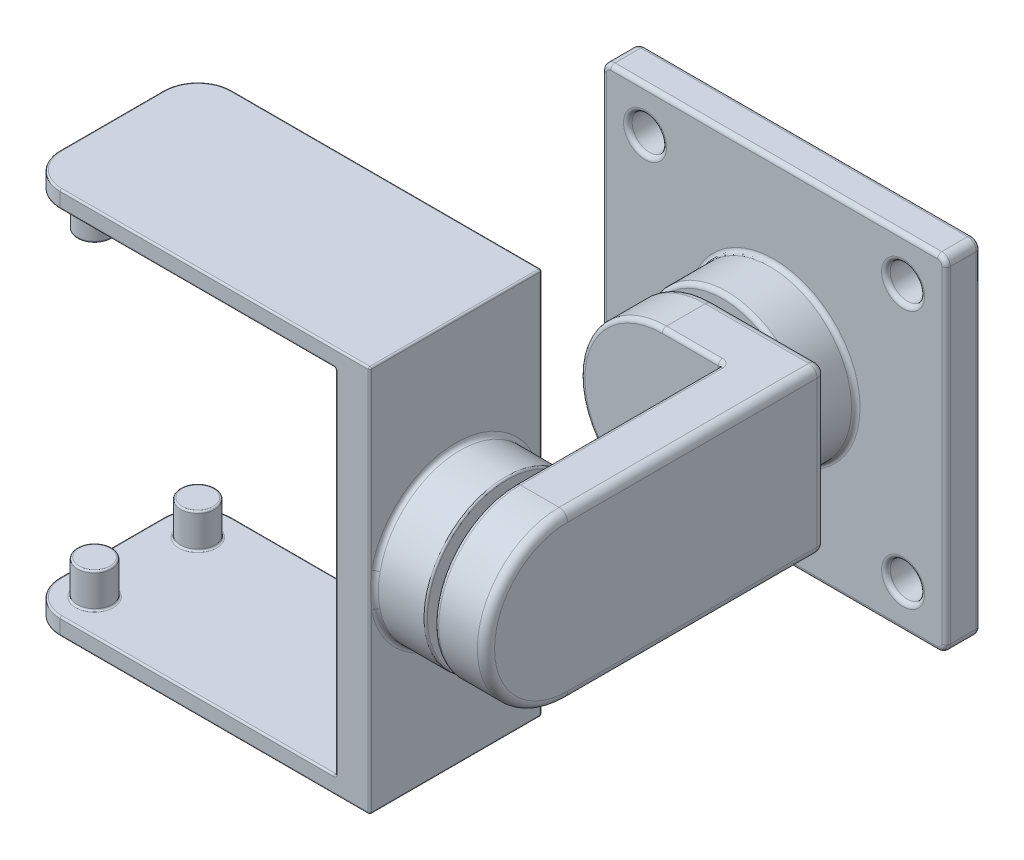
from build123d import *

# Parameters (mm, degrees)
BOSS_EXTRUDE1_DEPTH  = 10
BOSS_EXTRUDE2_START  = -10.25
SKETCH2_R            = 1
BOSS_EXTRUDE2_DEPTH  = 2
BOSS_EXTRUDE3_START  = 10.25
SKETCH2_2_R          = 1
BOSS_EXTRUDE3_DEPTH  = 2
FILLET1_R            = 2
FILLET2_R            = 0.1
SKETCH4_R            = 4.75
BOSS_EXTRUDE4_DEPTH  = 3
FILLET3_R            = 0.1
SKETCH5_R            = 3
BOSS_EXTRUDE5_DEPTH  = 0.5
SKETCH6_R            = 4.75
BOSS_EXTRUDE6_DEPTH  = 3
SKETCH7_W            = 15
SKETCH7_H            = 9.5
BOSS_EXTRUDE7_DEPTH  = 3
BOSS_EXTRUDE8_DEPTH  = 3
SKETCH10_R           = 3
BOSS_EXTRUDE9_DEPTH  = 0.5
SKETCH11_R           = 4.75
BOSS_EXTRUDE10_DEPTH = 3
SKETCH12_W           = 20
SKETCH12_H           = 20
BOSS_EXTRUDE11_DEPTH = 2
FILLET4_R            = 0.5
CUT_EXTRUDE1_REACH   = 27.5
SKETCH13_R           = 1
FILLET5_R            = 0.5
FILLET6_R            = 0.25


with BuildPart() as part:
    # Sketch1 → Boss-Extrude1 (new body)
    with BuildSketch(Plane.XY):
        Polygon((0, -10.25), (0, 10.25), (-18, 10.25), (-18, 11.25), (2, 11.25), (2, -11.25), (-18, -11.25), (-18, -10.25), align=None)
    extrude(amount=BOSS_EXTRUDE1_DEPTH)

    # Sketch2 → Boss-Extrude2 (add)
    with BuildSketch(Plane(origin=(0, 0, 0), x_dir=(1, 0, 0), z_dir=(0, 1, 0)).offset(BOSS_EXTRUDE2_START)):
        with Locations((-16, -2)):
            Circle(SKETCH2_R)
        with Locations((-16, -8)):
            Circle(SKETCH2_R)
    extrude(amount=BOSS_EXTRUDE2_DEPTH)

    # Sketch2_2 → Boss-Extrude3 (add)
    with BuildSketch(Plane(origin=(0, 0, 0), x_dir=(1, 0, 0), z_dir=(0, 1, 0)).offset(BOSS_EXTRUDE3_START)):
        with Locations((-16, -2)):
            Circle(SKETCH2_2_R)
        with Locations((-16, -8)):
            Circle(SKETCH2_2_R)
    extrude(amount=-BOSS_EXTRUDE3_DEPTH)

    # Fillet1
    fillet1_edges = [part.edges().sort_by_distance(p)[0] for p in [
        (-18, 10.75, 0),
        (-18, -10.75, 10),
        (-18, 10.75, 10),
        (-18, -10.75, 0),
    ]]
    fillet(fillet1_edges, radius=FILLET1_R)

    # Fillet2
    fillet2_edges = [part.edges().sort_by_distance(p)[0] for p in [
        (0, 0, 10),
        (-8, -10.25, 10),
        (2, 11.25, 5),
        (2, -11.25, 5),
        (0, -10.25, 5),
        (0, 10.25, 5),
        (2, 0, 10),
        (-17, -8.25, 2),
        (-17, -10.25, 2),
        (-7, 11.25, 10),
        (-17, -8.25, 8),
        (-17, -10.25, 8),
        (-17, 8.25, 2),
        (-17, 10.25, 2),
        (-17, 8.25, 8),
        (-17, 10.25, 8),
        (-8, 10.25, 10),
        (-7, -11.25, 10),
        (-7, -11.25, 0),
        (-18, -11.25, 5),
        (-17.414213562, -11.25, 0.585786438),
        (-17.414213562, -11.25, 9.414213562),
        (-18, -10.25, 5),
        (-17.414213562, -10.25, 0.585786438),
        (-17.414213562, -10.25, 9.414213562),
        (-8, 10.25, 0),
        (-18, 10.25, 5),
        (-17.414213562, 10.25, 0.585786438),
        (-17.414213562, 10.25, 9.414213562),
        (-18, 11.25, 5),
        (-17.414213562, 11.25, 0.585786438),
        (-17.414213562, 11.25, 9.414213562),
        (-7, 11.25, 0),
        (2, 0, 0),
        (-8, -10.25, 0),
        (0, 0, 0),
    ]]
    fillet(fillet2_edges, radius=FILLET2_R)

    # Sketch4 → Boss-Extrude4 (add)
    with BuildSketch(Plane(origin=(2, 0, 0), x_dir=(0, 0, -1), z_dir=(1, 0, 0))):
        with Locations((-5, 0)):
            Circle(SKETCH4_R)
    extrude(amount=BOSS_EXTRUDE4_DEPTH)

    # Fillet3
    fillet3_edges = [part.edges().sort_by_distance(p)[0] for p in [
        (5, 0, 9.75),
    ]]
    fillet(fillet3_edges, radius=FILLET3_R)

    # Sketch5 → Boss-Extrude5 (add)
    with BuildSketch(Plane(origin=(5, 0, 0), x_dir=(0, 0, -1), z_dir=(1, 0, 0))):
        with Locations((-5, 0)):
            Circle(SKETCH5_R)
    extrude(amount=BOSS_EXTRUDE5_DEPTH)

    # Sketch6 → Boss-Extrude6 (add)
    with BuildSketch(Plane(origin=(5.5, 0, 0), x_dir=(0, 0, -1), z_dir=(1, 0, 0))):
        with Locations((-5, 0)):
            Circle(SKETCH6_R)
    extrude(amount=BOSS_EXTRUDE6_DEPTH)

    # Sketch7 → Boss-Extrude7 (add)
    with BuildSketch(Plane(origin=(8.5, 0, 0), x_dir=(0, 0, -1), z_dir=(1, 0, 0))):
        with Locations((2.5, 0)):
            Rectangle(SKETCH7_W, SKETCH7_H)
    extrude(amount=-BOSS_EXTRUDE7_DEPTH)

    # Sketch9 → Boss-Extrude8 (add)
    with BuildSketch(Plane(origin=(0, 0, -10), x_dir=(-1, 0, 0), z_dir=(0, 0, -1))):
        with BuildLine():
            Line((-8.5, 4.75), (-2, 4.75))
            ThreePointArc((-2, 4.75), (2.75, 0), (-2, -4.75))
            Line((-2, -4.75), (-8.5, -4.75))
            Line((-8.5, -4.75), (-8.5, 4.75))
        make_face()
    extrude(amount=-BOSS_EXTRUDE8_DEPTH)

    # Sketch10 → Boss-Extrude9 (add)
    with BuildSketch(Plane(origin=(0, 0, -10), x_dir=(-1, 0, 0), z_dir=(0, 0, -1))):
        with Locations((-2, 0)):
            Circle(SKETCH10_R)
    extrude(amount=BOSS_EXTRUDE9_DEPTH)

    # Sketch11 → Boss-Extrude10 (add)
    with BuildSketch(Plane(origin=(0, 0, -10.5), x_dir=(-1, 0, 0), z_dir=(0, 0, -1))):
        with Locations((-2, 0)):
            Circle(SKETCH11_R)
    extrude(amount=BOSS_EXTRUDE10_DEPTH)

    # Sketch12 → Boss-Extrude11 (add)
    with BuildSketch(Plane(origin=(0, 0, -13.5), x_dir=(-1, 0, 0), z_dir=(0, 0, -1))):
        with Locations((-2, 0)):
            Rectangle(SKETCH12_W, SKETCH12_H)
    extrude(amount=BOSS_EXTRUDE11_DEPTH)

    # Fillet4
    fillet4_edges = [part.edges().sort_by_distance(p)[0] for p in [
        (-8, -10, -14.5),
        (-8, 10, -14.5),
        (12, 10, -14.5),
        (12, -10, -14.5),
    ]]
    fillet(fillet4_edges, radius=FILLET4_R)

    # Sketch13 → Cut-Extrude1 (cut, up to next)
    with BuildSketch(Plane(origin=(0, 0, -15.5), x_dir=(-1, 0, 0), z_dir=(0, 0, -1)), mode=Mode.PRIVATE) as cut_extrude1_sk1:
        with Locations((5.5, 7.5)):
            Circle(SKETCH13_R)
    cut_extrude1_tool1 = extrude(cut_extrude1_sk1.sketch, amount=-CUT_EXTRUDE1_REACH, mode=Mode.PRIVATE) & part.part
    add(cut_extrude1_tool1.solids().sort_by_distance((-5.5, 7.5, -15.5))[0], mode=Mode.SUBTRACT)
    # Sketch13 → Cut-Extrude1 (cut, up to next)
    with BuildSketch(Plane(origin=(0, 0, -15.5), x_dir=(-1, 0, 0), z_dir=(0, 0, -1)), mode=Mode.PRIVATE) as cut_extrude1_sk2:
        with Locations((-9.5, 7.5)):
            Circle(SKETCH13_R)
    cut_extrude1_tool2 = extrude(cut_extrude1_sk2.sketch, amount=-CUT_EXTRUDE1_REACH, mode=Mode.PRIVATE) & part.part
    add(cut_extrude1_tool2.solids().sort_by_distance((9.5, 7.5, -15.5))[0], mode=Mode.SUBTRACT)
    # Sketch13 → Cut-Extrude1 (cut, up to next)
    with BuildSketch(Plane(origin=(0, 0, -15.5), x_dir=(-1, 0, 0), z_dir=(0, 0, -1)), mode=Mode.PRIVATE) as cut_extrude1_sk3:
        with Locations((-9.5, -7.5)):
            Circle(SKETCH13_R)
    cut_extrude1_tool3 = extrude(cut_extrude1_sk3.sketch, amount=-CUT_EXTRUDE1_REACH, mode=Mode.PRIVATE) & part.part
    add(cut_extrude1_tool3.solids().sort_by_distance((9.5, -7.5, -15.5))[0], mode=Mode.SUBTRACT)
    # Sketch13 → Cut-Extrude1 (cut, up to next)
    with BuildSketch(Plane(origin=(0, 0, -15.5), x_dir=(-1, 0, 0), z_dir=(0, 0, -1)), mode=Mode.PRIVATE) as cut_extrude1_sk4:
        with Locations((5.5, -7.5)):
            Circle(SKETCH13_R)
    cut_extrude1_tool4 = extrude(cut_extrude1_sk4.sketch, amount=-CUT_EXTRUDE1_REACH, mode=Mode.PRIVATE) & part.part
    add(cut_extrude1_tool4.solids().sort_by_distance((-5.5, -7.5, -15.5))[0], mode=Mode.SUBTRACT)

    # Fillet5
    fillet5_edges = [part.edges().sort_by_distance(p)[0] for p in [
        (8.5, 0, 9.75),
        (5.25, 4.75, -10),
        (5.25, -4.75, -10),
        (8.5, -4.75, -2.5),
        (8.5, 0, -10),
        (8.5, 4.75, -2.5),
        (-2.75, 0, -10),
    ]]
    fillet(fillet5_edges, radius=FILLET5_R)

    # Fillet6
    fillet6_edges = [part.edges().sort_by_distance(p)[0] for p in [
        (2, 0, 9.75),
        (5.5, 0, 9.75),
        (5.5, 4.75, -1),
        (5.5, -4.75, -1),
        (3.75, 4.75, -7),
        (3.75, -4.75, -7),
        (5.5, 0, -7),
        (-2.75, 0, -7),
        (6.75, 0, -10.5),
        (6.75, 0, -13.5),
        (2, -10, -13.5),
        (2, -10, -15.5),
        (-8, 0, -13.5),
        (12, 0, -13.5),
        (2, 10, -13.5),
        (-7.853553391, 9.853553391, -13.5),
        (11.853553391, 9.853553391, -13.5),
        (-7.853553391, -9.853553391, -13.5),
        (11.853553391, -9.853553391, -13.5),
        (12, 0, -15.5),
        (-8, 0, -15.5),
        (2, 10, -15.5),
        (-7.853553391, 9.853553391, -15.5),
        (11.853553391, 9.853553391, -15.5),
        (-7.853553391, -9.853553391, -15.5),
        (11.853553391, -9.853553391, -15.5),
        (-4.5, -7.5, -15.5),
        (-4.5, -7.5, -13.5),
        (10.5, 7.5, -15.5),
        (10.5, 7.5, -13.5),
        (10.5, -7.5, -15.5),
        (10.5, -7.5, -13.5),
        (-4.5, 7.5, -15.5),
        (-4.5, 7.5, -13.5),
    ]]
    fillet(fillet6_edges, radius=FILLET6_R)


solid = part.part
